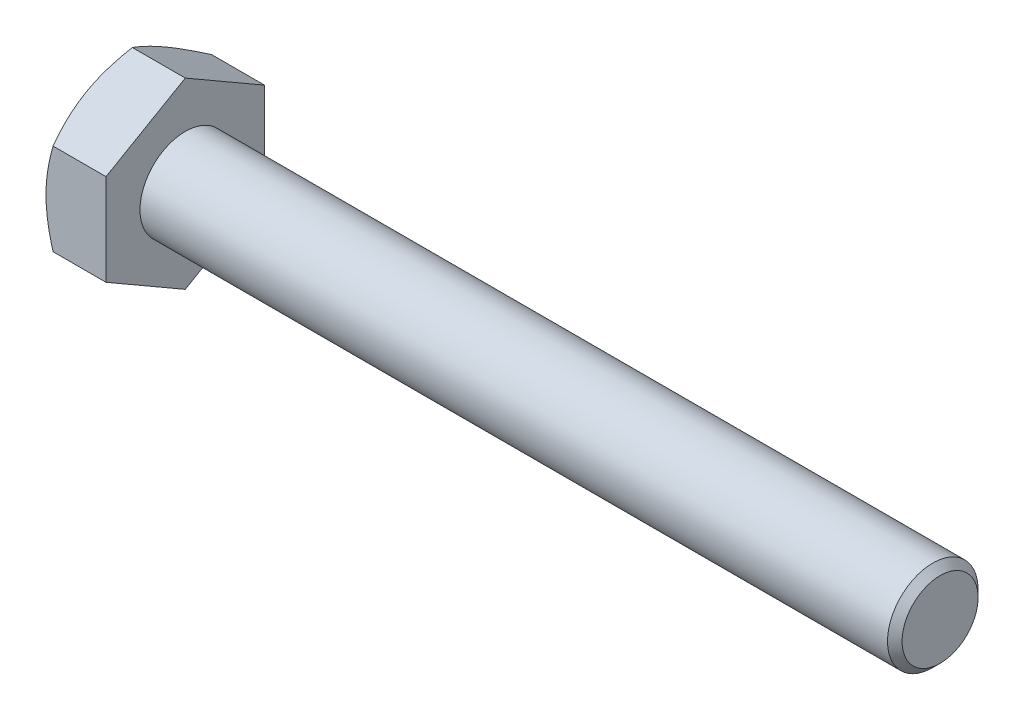
from build123d import *

# Parameters (mm, degrees)
BASEHEAD_DEPTH = 7.95


with BuildPart() as part:
    # Sketch1 → BaseHead (new body)
    with BuildSketch(Plane(origin=(0, 0, 0), x_dir=(0, 0, -1), z_dir=(1, 0, 0))):
        Polygon((10.5, 6.062177826), (10.5, -6.062177826), (0, -12.124355653), (-10.5, -6.062177826), (-10.5, 6.062177826), (0, 12.124355653), align=None)
    extrude(amount=BASEHEAD_DEPTH)

    # BodySke → BaseBody (revolve)
    with BuildSketch(Plane.XY):
        Polygon((0, 0), (107.95, 0), (107.95, 5.036), (106.986, 6), (0, 6), align=None)
    revolve(axis=Axis((0, 0, 0), (1, 0, 0)))

    # Sketch3 → HeadChamfer (revolve, cut)
    with BuildSketch(Plane.XY):
        Polygon((0, 10.5), (3.824573519, 17.124355653), (3.824573519, 22.124355653), (-10, 22.124355653), (-10, 10.5), align=None)
    revolve(axis=Axis((0, 0, 0), (1, 0, 0)), mode=Mode.SUBTRACT)


solid = part.part
